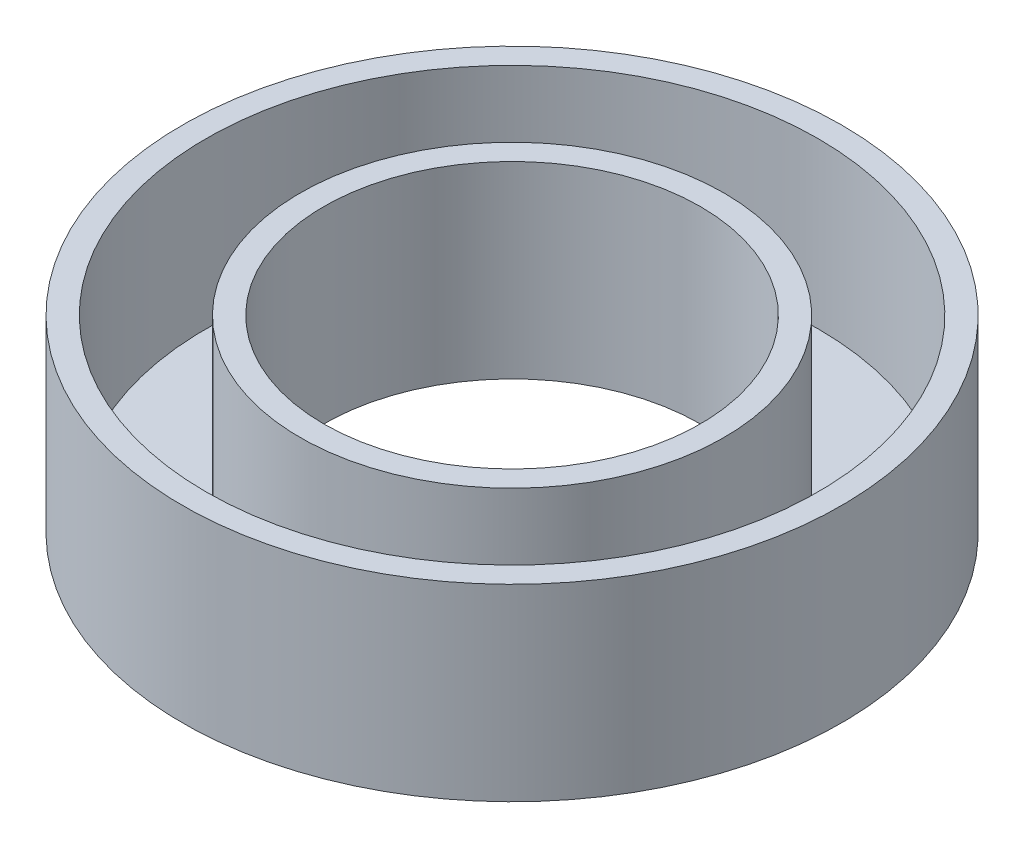
from build123d import *


with BuildPart() as part:
    # Sketch1 → Revolve1 (revolve)
    with BuildSketch(Plane.XY):
        Polygon((-11.1125, 6.35), (-11.1125, 0), (-6.35, 0), (-6.35, 6.35), (-7.14375, 6.35), (-7.14375, 0.79375), (-10.31875, 0.79375), (-10.31875, 6.35), align=None)
    revolve(axis=Axis((0, 0, 0), (0, 1, 0)))


solid = part.part
